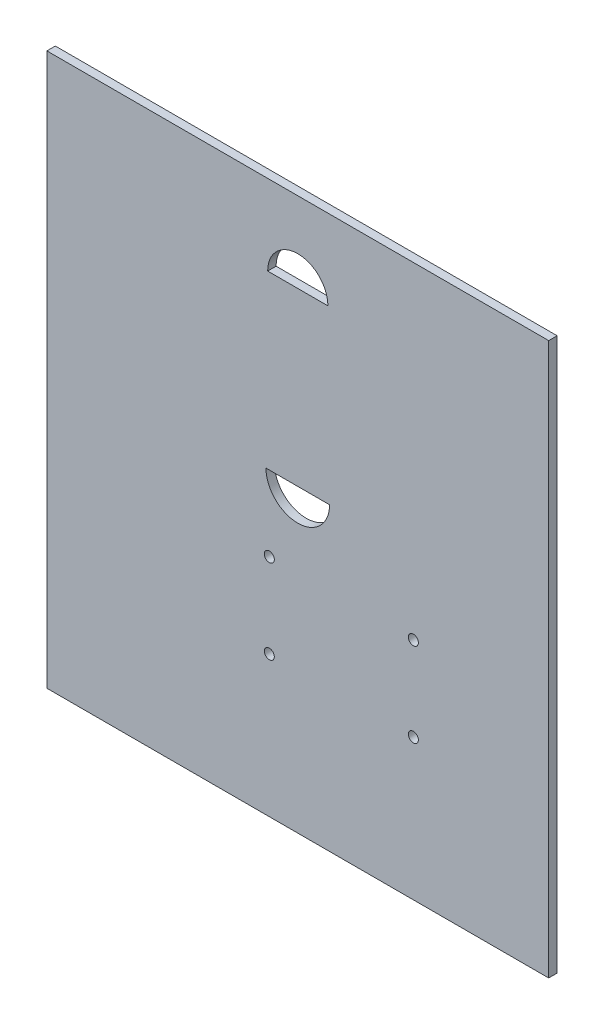
from build123d import *

# Parameters (mm, degrees)
SKETCH1_W               = 250
SKETCH1_H               = 275
BOSS_EXTRUDE1_DEPTH     = 4.2
ESQUISSE1_R             = 2.50000008
ENL_V_MAT_EXTRU_1_DEPTH = 5.2


with BuildPart() as part:
    # Sketch1 → Boss-Extrude1 (new body)
    with BuildSketch(Plane.XY):
        with Locations((-95.228215768, -27.385892116)):
            Rectangle(SKETCH1_W, SKETCH1_H)
    extrude(amount=BOSS_EXTRUDE1_DEPTH)

    # Esquisse1 → Enlèv. mat.-Extru.1 (cut, through all)
    with BuildSketch(Plane.XY.offset(4.2)):
        with Locations((-37.655669773, -94.649179191)):
            Circle(ESQUISSE1_R)
        with Locations((-37.655669773, -52.739179191)):
            Circle(ESQUISSE1_R)
        with Locations((-109.410669773, -94.649179191)):
            Circle(ESQUISSE1_R)
        with Locations((-109.410669773, -52.739179191)):
            Circle(ESQUISSE1_R)
        with BuildLine():
            Line((-110.228215768, 70.114107884), (-80.228215768, 70.114107884))
            ThreePointArc((-80.228215768, 70.114107884), (-95.228215768, 85.114107884), (-110.228215768, 70.114107884))
        make_face()
        with BuildLine():
            Line((-111.073893882, -15.305892116), (-79.382537653, -15.305892116))
            ThreePointArc((-79.382537653, -15.305892116), (-95.228215768, -31.151570231), (-111.073893882, -15.305892116))
        make_face()
    extrude(amount=-ENL_V_MAT_EXTRU_1_DEPTH, mode=Mode.SUBTRACT)


solid = part.part
